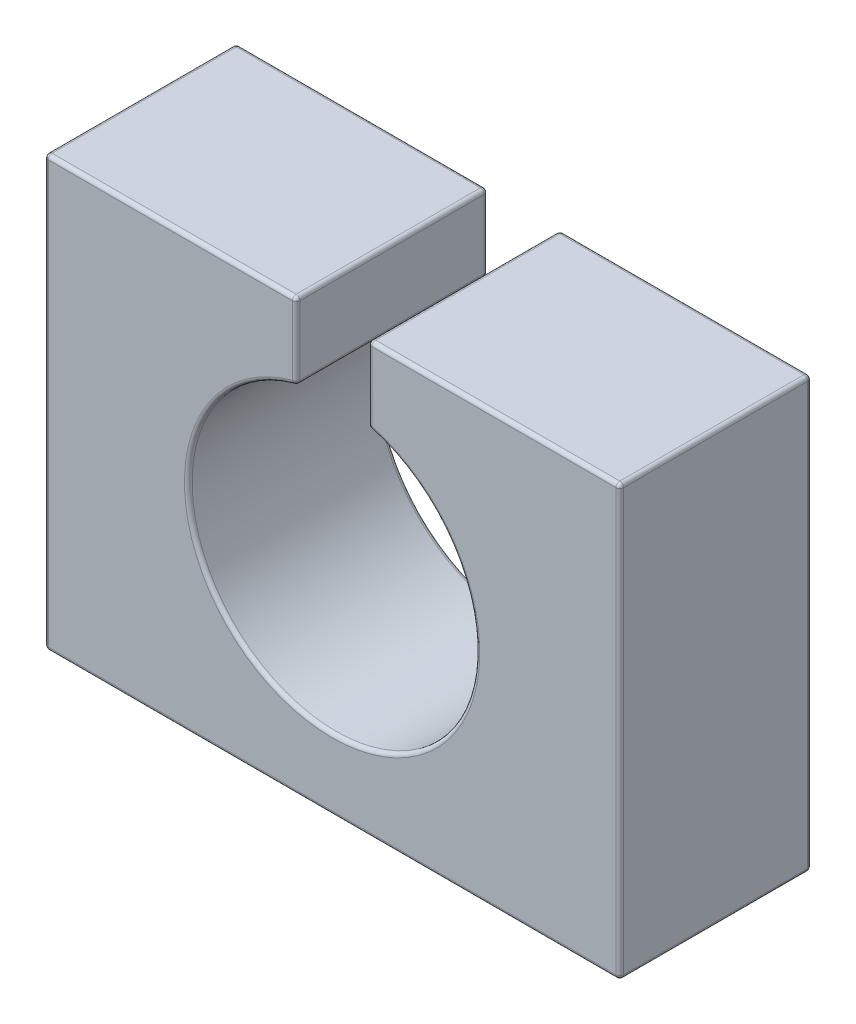
from build123d import *

# Parameters (mm, degrees)
SKETCH1_W           = 38.1
SKETCH1_H           = 28.448
BOSS_EXTRUDE1_DEPTH = 12.7
CUT_EXTRUDE2_REACH  = 14.7
FILLET1_R           = 0.254


with BuildPart() as part:
    # Sketch1 → Boss-Extrude1 (new body)
    with BuildSketch(Plane.XY):
        with Locations((19.05, 14.224)):
            Rectangle(SKETCH1_W, SKETCH1_H)
    extrude(amount=-BOSS_EXTRUDE1_DEPTH)

    # Sketch3 → Cut-Extrude2 (cut, up to next)
    with BuildSketch(Plane.XY, mode=Mode.PRIVATE) as cut_extrude2_sk1:
        with BuildLine():
            Line((16.66875, 28.448), (16.66875, 23.446541593))
            ThreePointArc((16.66875, 23.446541593), (19.05, 4.699), (21.43125, 23.446541593))
            Line((21.43125, 23.446541593), (21.43125, 28.448))
            Line((21.43125, 28.448), (16.66875, 28.448))
        make_face()
    cut_extrude2_tool1 = extrude(cut_extrude2_sk1.sketch, amount=-CUT_EXTRUDE2_REACH, mode=Mode.PRIVATE) & part.part
    add(cut_extrude2_tool1.solids().sort_by_distance((19.05, 15.101748, 0))[0], mode=Mode.SUBTRACT)

    # Fillet1
    fillet1_edges = [part.edges().sort_by_distance(p)[0] for p in [
        (38.1, 14.224, -12.7),
        (8.334375, 28.448, 0),
        (8.334375, 28.448, -12.7),
        (29.765625, 28.448, -12.7),
        (21.43125, 23.446541593, -6.35),
        (16.66875, 23.446541593, -6.35),
        (16.66875, 28.448, -6.35),
        (21.43125, 25.947270797, -12.7),
        (21.43125, 28.448, -6.35),
        (21.43125, 25.947270797, 0),
        (19.05, 4.699, 0),
        (16.66875, 25.947270797, 0),
        (19.05, 4.699, -12.7),
        (16.66875, 25.947270797, -12.7),
        (0, 14.224, -12.7),
        (29.765625, 28.448, 0),
        (38.1, 14.224, 0),
        (19.05, 0, 0),
        (0, 14.224, 0),
        (0, 28.448, -6.35),
        (38.1, 28.448, -6.35),
        (38.1, 0, -6.35),
        (0, 0, -6.35),
        (19.05, 0, -12.7),
    ]]
    fillet(fillet1_edges, radius=FILLET1_R)


solid = part.part
